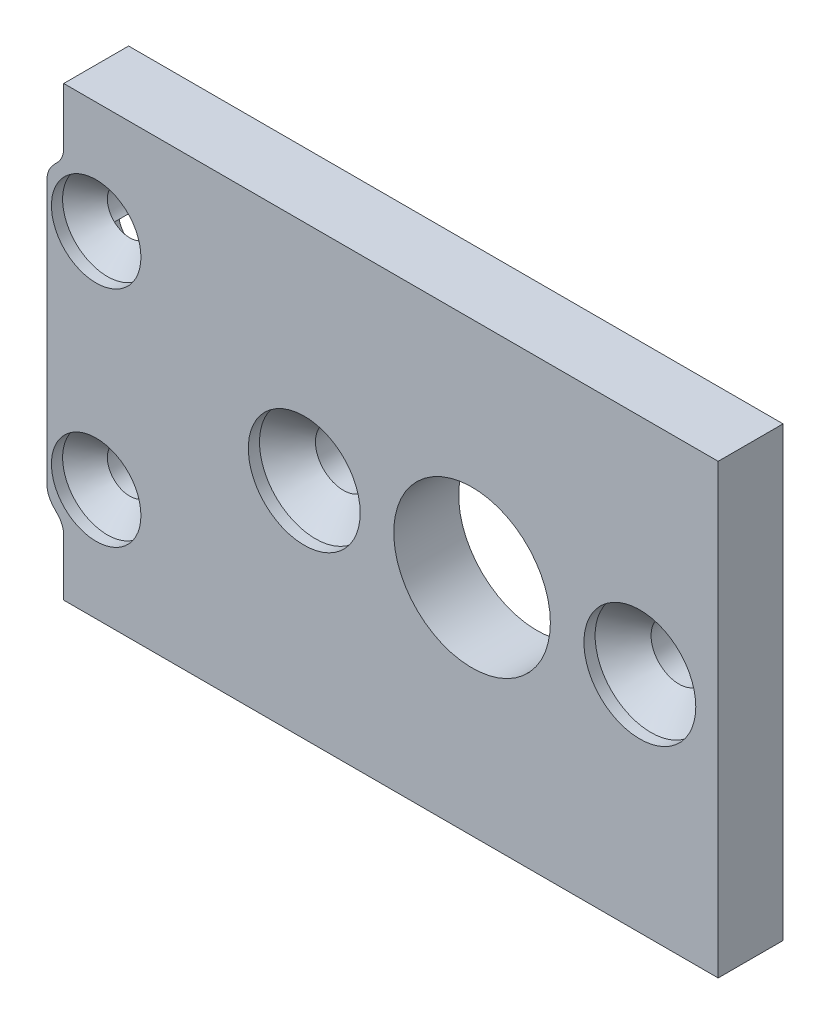
from build123d import *

# Parameters (mm, degrees)
SKETCH1_W                                      = 185
SKETCH1_H                                      = 20
BASE_SHAPE_DEPTH                               = 2.9
MOTOR_CUTOUTS_REACH                            = 95.084
SKETCH2_R                                      = 1.25
SKETCH2_R_2                                    = 3.5
SKETCH2_R_3                                    = 5
MOTOR_M2_5_COUNTERSUNKS_AT_2_COUNT             = 2
MOTOR_M2_5_COUNTERSUNKS_AT_2_PITCH             = 15
MOTOR_M2_5_COUNTERSUNKS_AT_3_COUNT             = 2
MOTOR_M2_5_COUNTERSUNKS_AT_3_PITCH             = 147.666008275
MOTOR_M2_5_COUNTERSUNKS_AT_4_COUNT             = 2
MOTOR_M2_5_COUNTERSUNKS_AT_4_PITCH             = 161.651631603
MOTOR_M2_5_COUNTERSUNKS_AT_5_COUNT             = 2
MOTOR_M2_5_COUNTERSUNKS_AT_5_PITCH             = 147.666008275
MOTOR_M2_5_COUNTERSUNKS_AT_6_COUNT             = 2
MOTOR_M2_5_COUNTERSUNKS_AT_6_PITCH             = 161.651631603
PCB_SLOT_DEPTH                                 = 0.775
END_PLATE_HOLES_REACH                          = 95.084
SKETCH6_R                                      = 1
CSK_FOR_M2_FLAT_HEAD_MACHINE_SCREW3_AT_2_COUNT = 2
CSK_FOR_M2_FLAT_HEAD_MACHINE_SCREW3_AT_2_PITCH = 10
CSK_FOR_M2_FLAT_HEAD_MACHINE_SCREW3_AT_3_COUNT = 2
CSK_FOR_M2_FLAT_HEAD_MACHINE_SCREW3_AT_3_PITCH = 180.6
CSK_FOR_M2_FLAT_HEAD_MACHINE_SCREW3_AT_4_COUNT = 2
CSK_FOR_M2_FLAT_HEAD_MACHINE_SCREW3_AT_4_PITCH = 180.876643047
TAP_SLOTS_DEPTH                                = 1.4
CUT_EXTRUDE3_REACH                             = 95.084
FILLET1_R                                      = 1
CUT_EXTRUDE4_REACH                             = 95.084
SKETCH14_W                                     = 155
SKETCH14_H                                     = 20


with BuildPart() as part:
    # Sketch1 → Base shape (new body)
    with BuildSketch(Plane.XY):
        Rectangle(SKETCH1_W, SKETCH1_H)
    extrude(amount=-BASE_SHAPE_DEPTH)

    # Sketch2 → Motor cutouts (cut, up to next)
    with BuildSketch(Plane.XY, mode=Mode.PRIVATE) as motor_cutouts_sk1:
        with Locations((-81, 0)):
            Circle(SKETCH2_R)
    motor_cutouts_tool1 = extrude(motor_cutouts_sk1.sketch, amount=-MOTOR_CUTOUTS_REACH, mode=Mode.PRIVATE) & part.part
    # Sketch2 → Motor cutouts (cut, up to next)
    with BuildSketch(Plane.XY, mode=Mode.PRIVATE) as motor_cutouts_sk2:
        with Locations((-66, 0)):
            Circle(SKETCH2_R)
    motor_cutouts_tool2 = extrude(motor_cutouts_sk2.sketch, amount=-MOTOR_CUTOUTS_REACH, mode=Mode.PRIVATE) & part.part
    # Sketch2 → Motor cutouts (cut, up to next)
    with BuildSketch(Plane.XY, mode=Mode.PRIVATE) as motor_cutouts_sk3:
        with Locations((-73.5, 0)):
            Circle(SKETCH2_R_2)
    motor_cutouts_tool3 = extrude(motor_cutouts_sk3.sketch, amount=-MOTOR_CUTOUTS_REACH, mode=Mode.PRIVATE) & part.part
    # Sketch2 → Motor cutouts (cut, up to next)
    with BuildSketch(Plane.XY, mode=Mode.PRIVATE) as motor_cutouts_sk4:
        with Locations((73.5, 0)):
            Circle(SKETCH2_R_3)
    motor_cutouts_tool4 = extrude(motor_cutouts_sk4.sketch, amount=-MOTOR_CUTOUTS_REACH, mode=Mode.PRIVATE) & part.part
    # Sketch2 → Motor cutouts (cut, up to next)
    with BuildSketch(Plane.XY, mode=Mode.PRIVATE) as motor_cutouts_sk5:
        with Locations((66.5, 7)):
            Circle(SKETCH2_R)
    motor_cutouts_tool5 = extrude(motor_cutouts_sk5.sketch, amount=-MOTOR_CUTOUTS_REACH, mode=Mode.PRIVATE) & part.part
    # Sketch2 → Motor cutouts (cut, up to next)
    with BuildSketch(Plane.XY, mode=Mode.PRIVATE) as motor_cutouts_sk6:
        with Locations((80.5, 7)):
            Circle(SKETCH2_R)
    motor_cutouts_tool6 = extrude(motor_cutouts_sk6.sketch, amount=-MOTOR_CUTOUTS_REACH, mode=Mode.PRIVATE) & part.part
    # Sketch2 → Motor cutouts (cut, up to next)
    with BuildSketch(Plane.XY, mode=Mode.PRIVATE) as motor_cutouts_sk7:
        with Locations((80.5, -7)):
            Circle(SKETCH2_R)
    motor_cutouts_tool7 = extrude(motor_cutouts_sk7.sketch, amount=-MOTOR_CUTOUTS_REACH, mode=Mode.PRIVATE) & part.part
    # Sketch2 → Motor cutouts (cut, up to next)
    with BuildSketch(Plane.XY, mode=Mode.PRIVATE) as motor_cutouts_sk8:
        with Locations((66.5, -7)):
            Circle(SKETCH2_R)
    motor_cutouts_tool8 = extrude(motor_cutouts_sk8.sketch, amount=-MOTOR_CUTOUTS_REACH, mode=Mode.PRIVATE) & part.part
    add(motor_cutouts_tool1.solids().sort_by_distance((-81, 0, 0))[0], mode=Mode.SUBTRACT)
    add(motor_cutouts_tool2.solids().sort_by_distance((-66, 0, 0))[0], mode=Mode.SUBTRACT)
    add(motor_cutouts_tool3.solids().sort_by_distance((-73.5, 0, 0))[0], mode=Mode.SUBTRACT)
    add(motor_cutouts_tool4.solids().sort_by_distance((73.5, 0, 0))[0], mode=Mode.SUBTRACT)
    add(motor_cutouts_tool5.solids().sort_by_distance((66.5, 7, 0))[0], mode=Mode.SUBTRACT)
    add(motor_cutouts_tool6.solids().sort_by_distance((80.5, 7, 0))[0], mode=Mode.SUBTRACT)
    add(motor_cutouts_tool7.solids().sort_by_distance((80.5, -7, 0))[0], mode=Mode.SUBTRACT)
    add(motor_cutouts_tool8.solids().sort_by_distance((66.5, -7, 0))[0], mode=Mode.SUBTRACT)

    # Sketch4 → Motor M2.5 countersunks (revolve, cut)
    with BuildSketch(Plane(origin=(-81, 0, 0), x_dir=(0, -1, 0), z_dir=(1, 0, 0))):
        Polygon((0, 0), (0, 2.9), (1.25, 2.9), (1.25, 1.75), (2.5, 0.5), (2.5, 0), align=None)
    motor_m2_5_countersunks = revolve(axis=Axis((-81, 0, 6.35), (0, 0, -1)), mode=Mode.SUBTRACT)

    # Motor M2.5 countersunks at 2: Motor M2.5 countersunks ×2
    with Locations(*[(i * MOTOR_M2_5_COUNTERSUNKS_AT_2_PITCH, 0, 0) for i in range(1, MOTOR_M2_5_COUNTERSUNKS_AT_2_COUNT)]):
        add(motor_m2_5_countersunks, mode=Mode.SUBTRACT)

    # Motor M2.5 countersunks at 3: Motor M2.5 countersunks ×2
    with Locations(*[Vector(0.9988757854473691, 0.047404274563603965, 0) * (i * MOTOR_M2_5_COUNTERSUNKS_AT_3_PITCH) for i in range(1, MOTOR_M2_5_COUNTERSUNKS_AT_3_COUNT)]):
        add(motor_m2_5_countersunks, mode=Mode.SUBTRACT)

    # Motor M2.5 countersunks at 4: Motor M2.5 countersunks ×2
    with Locations(*[Vector(0.9990619853213468, 0.043302996267798335, 0) * (i * MOTOR_M2_5_COUNTERSUNKS_AT_4_PITCH) for i in range(1, MOTOR_M2_5_COUNTERSUNKS_AT_4_COUNT)]):
        add(motor_m2_5_countersunks, mode=Mode.SUBTRACT)

    # Motor M2.5 countersunks at 5: Motor M2.5 countersunks ×2
    with Locations(*[Vector(0.9988757854473691, -0.04740427456360395, 0) * (i * MOTOR_M2_5_COUNTERSUNKS_AT_5_PITCH) for i in range(1, MOTOR_M2_5_COUNTERSUNKS_AT_5_COUNT)]):
        add(motor_m2_5_countersunks, mode=Mode.SUBTRACT)

    # Motor M2.5 countersunks at 6: Motor M2.5 countersunks ×2
    with Locations(*[Vector(0.9990619853213468, -0.0433029962677983, 0) * (i * MOTOR_M2_5_COUNTERSUNKS_AT_6_PITCH) for i in range(1, MOTOR_M2_5_COUNTERSUNKS_AT_6_COUNT)]):
        add(motor_m2_5_countersunks, mode=Mode.SUBTRACT)

    # Sketch5 → PCB slot (cut)
    with BuildSketch(Plane(origin=(0, 0, -2.9), x_dir=(-1, 0, 0), z_dir=(0, 0, -1))):
        with BuildLine():
            Line((-60, -6), (60, -6))
            ThreePointArc((60, -6), (61, -7), (60, -8))
            Line((60, -8), (-60, -8))
            ThreePointArc((-60, -8), (-61, -7), (-60, -6))
        make_face()
    extrude(amount=-PCB_SLOT_DEPTH, mode=Mode.SUBTRACT)

    # Sketch6 → End plate holes (cut, up to next)
    with BuildSketch(Plane.XY, mode=Mode.PRIVATE) as end_plate_holes_sk1:
        with Locations((90.3, 5)):
            Circle(SKETCH6_R)
    end_plate_holes_tool1 = extrude(end_plate_holes_sk1.sketch, amount=-END_PLATE_HOLES_REACH, mode=Mode.PRIVATE) & part.part
    # Sketch6 → End plate holes (cut, up to next)
    with BuildSketch(Plane.XY, mode=Mode.PRIVATE) as end_plate_holes_sk2:
        with Locations((90.3, -5)):
            Circle(SKETCH6_R)
    end_plate_holes_tool2 = extrude(end_plate_holes_sk2.sketch, amount=-END_PLATE_HOLES_REACH, mode=Mode.PRIVATE) & part.part
    # Sketch6 → End plate holes (cut, up to next)
    with BuildSketch(Plane.XY, mode=Mode.PRIVATE) as end_plate_holes_sk3:
        with Locations((-90.3, -5)):
            Circle(SKETCH6_R)
    end_plate_holes_tool3 = extrude(end_plate_holes_sk3.sketch, amount=-END_PLATE_HOLES_REACH, mode=Mode.PRIVATE) & part.part
    # Sketch6 → End plate holes (cut, up to next)
    with BuildSketch(Plane.XY, mode=Mode.PRIVATE) as end_plate_holes_sk4:
        with Locations((-90.3, 5)):
            Circle(SKETCH6_R)
    end_plate_holes_tool4 = extrude(end_plate_holes_sk4.sketch, amount=-END_PLATE_HOLES_REACH, mode=Mode.PRIVATE) & part.part
    add(end_plate_holes_tool1.solids().sort_by_distance((90.3, 5, 0))[0], mode=Mode.SUBTRACT)
    add(end_plate_holes_tool2.solids().sort_by_distance((90.3, -5, 0))[0], mode=Mode.SUBTRACT)
    add(end_plate_holes_tool3.solids().sort_by_distance((-90.3, -5, 0))[0], mode=Mode.SUBTRACT)
    add(end_plate_holes_tool4.solids().sort_by_distance((-90.3, 5, 0))[0], mode=Mode.SUBTRACT)

    # Sketch9 → CSK for M2 Flat Head Machine Screw3 (revolve, cut)
    with BuildSketch(Plane(origin=(90.3, 5, 0), x_dir=(0, -1, 0), z_dir=(1, 0, 0))):
        Polygon((0, 0), (0, 2.9), (1, 2.9), (1, 1.5), (2, 0.5), (2, 0), align=None)
    csk_for_m2_flat_head_machine_screw3 = revolve(axis=Axis((90.3, 5, 6.35), (0, 0, -1)), mode=Mode.SUBTRACT)

    # CSK for M2 Flat Head Machine Screw3 at 2: CSK for M2 Flat Head Machine Screw3 ×2
    with Locations(*[(0, -i * CSK_FOR_M2_FLAT_HEAD_MACHINE_SCREW3_AT_2_PITCH, 0) for i in range(1, CSK_FOR_M2_FLAT_HEAD_MACHINE_SCREW3_AT_2_COUNT)]):
        add(csk_for_m2_flat_head_machine_screw3, mode=Mode.SUBTRACT)

    # CSK for M2 Flat Head Machine Screw3 at 3: CSK for M2 Flat Head Machine Screw3 ×2
    with Locations(*[(-i * CSK_FOR_M2_FLAT_HEAD_MACHINE_SCREW3_AT_3_PITCH, 0, 0) for i in range(1, CSK_FOR_M2_FLAT_HEAD_MACHINE_SCREW3_AT_3_COUNT)]):
        add(csk_for_m2_flat_head_machine_screw3, mode=Mode.SUBTRACT)

    # CSK for M2 Flat Head Machine Screw3 at 4: CSK for M2 Flat Head Machine Screw3 ×2
    with Locations(*[Vector(-0.9984705430039356, -0.055286298062233535, 0) * (i * CSK_FOR_M2_FLAT_HEAD_MACHINE_SCREW3_AT_4_PITCH) for i in range(1, CSK_FOR_M2_FLAT_HEAD_MACHINE_SCREW3_AT_4_COUNT)]):
        add(csk_for_m2_flat_head_machine_screw3, mode=Mode.SUBTRACT)

    # Sketch12 → Tap slots (cut)
    with BuildSketch(Plane(origin=(0, 0, -2.9), x_dir=(-1, 0, 0), z_dir=(0, 0, -1))):
        with BuildLine():
            ThreePointArc((-90.984432764, 4.270924015), (-92.07157644, 3.770298494), (-91.9, 2.585786438))
            Line((-91.9, 2.585786438), (-91.9, -2.585786438))
            ThreePointArc((-91.9, -2.585786438), (-92.07157644, -3.770298494), (-90.984432764, -4.270924015))
            ThreePointArc((-90.984432764, -4.270924015), (-90.3, -4), (-89.615567236, -4.270924015))
            ThreePointArc((-89.615567236, -4.270924015), (-88.52842356, -3.770298494), (-88.7, -2.585786438))
            Line((-88.7, -2.585786438), (-88.7, 2.585786438))
            ThreePointArc((-88.7, 2.585786438), (-88.52842356, 3.770298494), (-89.615567236, 4.270924015))
            ThreePointArc((-89.615567236, 4.270924015), (-90.3, 4), (-90.984432764, 4.270924015))
        make_face()
        with BuildLine():
            ThreePointArc((90.984432764, -4.270924015), (92.07157644, -3.770298494), (91.9, -2.585786438))
            Line((91.9, -2.585786438), (91.9, 2.585786438))
            ThreePointArc((91.9, 2.585786438), (92.07157644, 3.770298494), (90.984432764, 4.270924015))
            ThreePointArc((90.984432764, 4.270924015), (90.3, 4), (89.615567236, 4.270924015))
            ThreePointArc((89.615567236, 4.270924015), (88.52842356, 3.770298494), (88.7, 2.585786438))
            Line((88.7, 2.585786438), (88.7, -2.585786438))
            ThreePointArc((88.7, -2.585786438), (88.52842356, -3.770298494), (89.615567236, -4.270924015))
            ThreePointArc((89.615567236, -4.270924015), (90.3, -4), (90.984432764, -4.270924015))
        make_face()
    extrude(amount=-TAP_SLOTS_DEPTH, mode=Mode.SUBTRACT)

    # Sketch13 → Cut-Extrude3 (cut, up to next)
    with BuildSketch(Plane.XY, mode=Mode.PRIVATE) as cut_extrude3_sk1:
        with BuildLine():
            Line((-91.75, 10), (-92.5, 10))
            Line((-92.5, 10), (-92.5, 6.187434209))
            ThreePointArc((-92.5, 6.187434209), (-92.173731748, 6.655031521), (-91.75, 7.036541185))
            Line((-91.75, 7.036541185), (-91.75, 10))
        make_face()
    cut_extrude3_tool1 = extrude(cut_extrude3_sk1.sketch, amount=-CUT_EXTRUDE3_REACH, mode=Mode.PRIVATE) & part.part
    # Sketch13 → Cut-Extrude3 (cut, up to next)
    with BuildSketch(Plane.XY, mode=Mode.PRIVATE) as cut_extrude3_sk2:
        with BuildLine():
            ThreePointArc((-91.75, -7.036541185), (-92.173731748, -6.655031521), (-92.5, -6.187434209))
            Line((-92.5, -6.187434209), (-92.5, -10))
            Line((-92.5, -10), (-91.75, -10))
            Line((-91.75, -10), (-91.75, -7.036541185))
        make_face()
    cut_extrude3_tool2 = extrude(cut_extrude3_sk2.sketch, amount=-CUT_EXTRUDE3_REACH, mode=Mode.PRIVATE) & part.part
    # Sketch13 → Cut-Extrude3 (cut, up to next)
    with BuildSketch(Plane.XY, mode=Mode.PRIVATE) as cut_extrude3_sk3:
        with BuildLine():
            Line((92.5, 10), (91.75, 10))
            Line((91.75, 10), (91.75, 7.036541185))
            ThreePointArc((91.75, 7.036541185), (92.173731748, 6.655031521), (92.5, 6.187434209))
            Line((92.5, 6.187434209), (92.5, 10))
        make_face()
    cut_extrude3_tool3 = extrude(cut_extrude3_sk3.sketch, amount=-CUT_EXTRUDE3_REACH, mode=Mode.PRIVATE) & part.part
    # Sketch13 → Cut-Extrude3 (cut, up to next)
    with BuildSketch(Plane.XY, mode=Mode.PRIVATE) as cut_extrude3_sk4:
        with BuildLine():
            ThreePointArc((92.5, -6.187434209), (92.173731748, -6.655031521), (91.75, -7.036541185))
            Line((91.75, -7.036541185), (91.75, -10))
            Line((91.75, -10), (92.5, -10))
            Line((92.5, -10), (92.5, -6.187434209))
        make_face()
    cut_extrude3_tool4 = extrude(cut_extrude3_sk4.sketch, amount=-CUT_EXTRUDE3_REACH, mode=Mode.PRIVATE) & part.part
    add(cut_extrude3_tool1.solids().sort_by_distance((-92.140588, 8.330084, 0))[0], mode=Mode.SUBTRACT)
    add(cut_extrude3_tool2.solids().sort_by_distance((-92.140588, -8.330084, 0))[0], mode=Mode.SUBTRACT)
    add(cut_extrude3_tool3.solids().sort_by_distance((92.140588, 8.330084, 0))[0], mode=Mode.SUBTRACT)
    add(cut_extrude3_tool4.solids().sort_by_distance((92.140588, -8.330084, 0))[0], mode=Mode.SUBTRACT)

    # Fillet1
    fillet1_edges = [part.edges().sort_by_distance(p)[0] for p in [
        (-91.75, 7.036541185, -1.45),
        (-92.5, 6.187434209, -1.45),
        (-92.5, -6.187434209, -1.45),
        (-91.75, -7.036541185, -1.45),
        (91.75, 7.036541185, -1.45),
        (92.5, 6.187434209, -1.45),
        (92.5, -6.187434209, -1.45),
        (91.75, -7.036541185, -1.45),
    ]]
    fillet(fillet1_edges, radius=FILLET1_R)

    # Sketch14 → Cut-Extrude4 (cut, up to next)
    with BuildSketch(Plane.XY, mode=Mode.PRIVATE) as cut_extrude4_sk1:
        with Locations((15, 0)):
            Rectangle(SKETCH14_W, SKETCH14_H)
    cut_extrude4_tool1 = extrude(cut_extrude4_sk1.sketch, amount=-CUT_EXTRUDE4_REACH, mode=Mode.PRIVATE) & part.part
    add(cut_extrude4_tool1.solids().sort_by_distance((15, 0, 0))[0], mode=Mode.SUBTRACT)


solid = part.part
